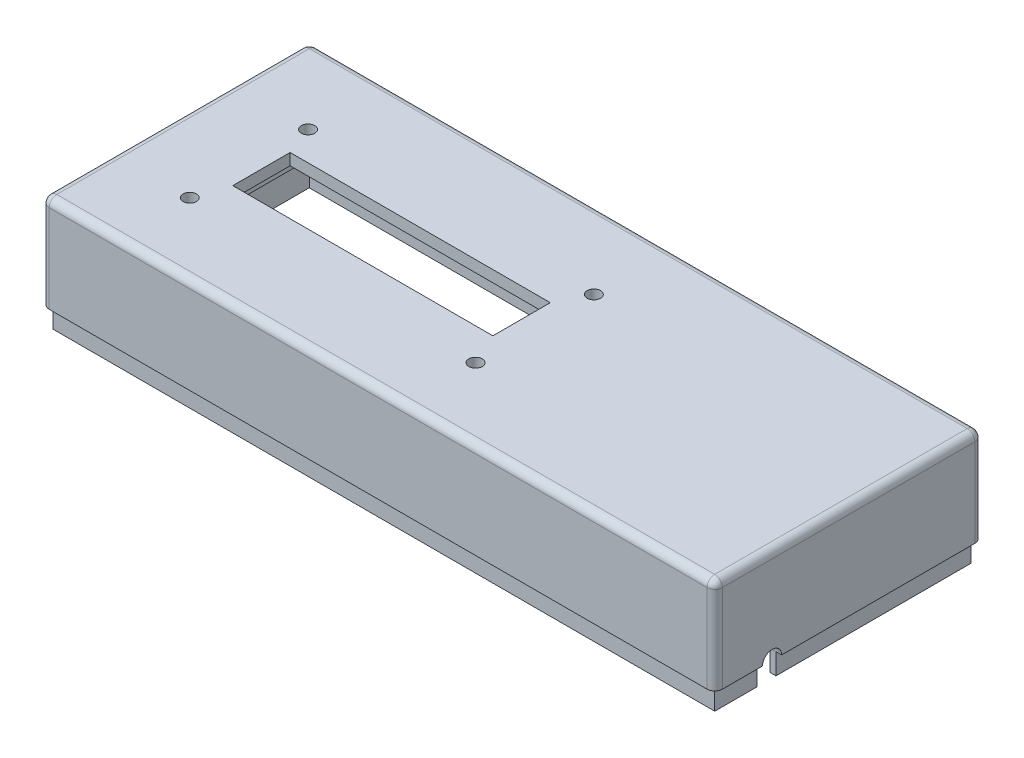
from build123d import *

# Parameters (mm, degrees)
SKETCH1_W           = 176
SKETCH1_H           = 70
BOSS_EXTRUDE1_DEPTH = 30.5
SKETCH2_W           = 170
SKETCH2_H           = 64
CUT_EXTRUDE1_DEPTH  = 27.5
SKETCH3_W           = 176
SKETCH3_H           = 70
SKETCH3_W_2         = 173
SKETCH3_H_2         = 67
CUT_EXTRUDE2_DEPTH  = 5.5
FILLET1_R           = 2
SKETCH4_W           = 78
SKETCH4_H           = 31
SKETCH4_W_2         = 72
SKETCH4_H_2         = 25
BOSS_EXTRUDE2_DEPTH = 3
CUT_EXTRUDE3_REACH  = 5
SKETCH5_W           = 68
SKETCH5_H           = 15
CUT_EXTRUDE4_REACH  = 32.5
SKETCH6_R           = 1.75
CUT_EXTRUDE6_REACH  = 178


with BuildPart() as part:
    # Sketch1 → Boss-Extrude1 (new body)
    with BuildSketch(Plane(origin=(0, 0, 0), x_dir=(1, 0, 0), z_dir=(0, 1, 0))):
        Rectangle(SKETCH1_W, SKETCH1_H)
    extrude(amount=BOSS_EXTRUDE1_DEPTH)

    # Sketch2 → Cut-Extrude1 (cut)
    with BuildSketch(Plane.XZ):
        Rectangle(SKETCH2_W, SKETCH2_H)
    extrude(amount=-CUT_EXTRUDE1_DEPTH, mode=Mode.SUBTRACT)

    # Sketch3 → Cut-Extrude2 (cut)
    with BuildSketch(Plane.XZ):
        Rectangle(SKETCH3_W, SKETCH3_H)
        Rectangle(SKETCH3_W_2, SKETCH3_H_2, mode=Mode.SUBTRACT)
    extrude(amount=-CUT_EXTRUDE2_DEPTH, mode=Mode.SUBTRACT)

    # Fillet1
    fillet1_edges = [part.edges().sort_by_distance(p)[0] for p in [
        (88, 30.5, 0),
        (0, 30.5, -35),
        (-88, 30.5, 0),
        (-88, 18, -35),
        (88, 18, -35),
        (88, 18, 35),
        (-88, 18, 35),
        (0, 30.5, 35),
    ]]
    fillet(fillet1_edges, radius=FILLET1_R)

    # Sketch4 → Boss-Extrude2 (add)
    with BuildSketch(Plane.XZ.offset(-27.5)):
        with Locations((-31, 0.5)):
            Rectangle(SKETCH4_W, SKETCH4_H)
        with Locations((-31, 0.5)):
            Rectangle(SKETCH4_W_2, SKETCH4_H_2, mode=Mode.SUBTRACT)
    extrude(amount=BOSS_EXTRUDE2_DEPTH)

    # Sketch5 → Cut-Extrude3 (cut, up to next)
    with BuildSketch(Plane.XZ.offset(-27.5), mode=Mode.PRIVATE) as cut_extrude3_sk1:
        with Locations((-31, 0.5)):
            Rectangle(SKETCH5_W, SKETCH5_H)
    cut_extrude3_tool1 = extrude(cut_extrude3_sk1.sketch, amount=-CUT_EXTRUDE3_REACH, mode=Mode.PRIVATE) & part.part
    add(cut_extrude3_tool1.solids().sort_by_distance((-31, 27.5, 0.5))[0], mode=Mode.SUBTRACT)

    # Sketch6 → Cut-Extrude4 (cut, up to next)
    with BuildSketch(Plane(origin=(0, 30.5, 0), x_dir=(1, 0, 0), z_dir=(0, 1, 0)), mode=Mode.PRIVATE) as cut_extrude4_sk1:
        with Locations((-67.88, 14.57)):
            Circle(SKETCH6_R)
    cut_extrude4_tool1 = extrude(cut_extrude4_sk1.sketch, amount=-CUT_EXTRUDE4_REACH, mode=Mode.PRIVATE) & part.part
    add(cut_extrude4_tool1.solids().sort_by_distance((-67.88, 30.5, -14.57))[0], mode=Mode.SUBTRACT)
    # Sketch6 → Cut-Extrude4 (cut, up to next)
    with BuildSketch(Plane(origin=(0, 30.5, 0), x_dir=(1, 0, 0), z_dir=(0, 1, 0)), mode=Mode.PRIVATE) as cut_extrude4_sk2:
        with Locations((6.83, 14.57)):
            Circle(SKETCH6_R)
    cut_extrude4_tool2 = extrude(cut_extrude4_sk2.sketch, amount=-CUT_EXTRUDE4_REACH, mode=Mode.PRIVATE) & part.part
    add(cut_extrude4_tool2.solids().sort_by_distance((6.83, 30.5, -14.57))[0], mode=Mode.SUBTRACT)
    # Sketch6 → Cut-Extrude4 (cut, up to next)
    with BuildSketch(Plane(origin=(0, 30.5, 0), x_dir=(1, 0, 0), z_dir=(0, 1, 0)), mode=Mode.PRIVATE) as cut_extrude4_sk3:
        with Locations((6.83, -16.36)):
            Circle(SKETCH6_R)
    cut_extrude4_tool3 = extrude(cut_extrude4_sk3.sketch, amount=-CUT_EXTRUDE4_REACH, mode=Mode.PRIVATE) & part.part
    add(cut_extrude4_tool3.solids().sort_by_distance((6.83, 30.5, 16.36))[0], mode=Mode.SUBTRACT)
    # Sketch6 → Cut-Extrude4 (cut, up to next)
    with BuildSketch(Plane(origin=(0, 30.5, 0), x_dir=(1, 0, 0), z_dir=(0, 1, 0)), mode=Mode.PRIVATE) as cut_extrude4_sk4:
        with Locations((-67.88, -16.36)):
            Circle(SKETCH6_R)
    cut_extrude4_tool4 = extrude(cut_extrude4_sk4.sketch, amount=-CUT_EXTRUDE4_REACH, mode=Mode.PRIVATE) & part.part
    add(cut_extrude4_tool4.solids().sort_by_distance((-67.88, 30.5, 16.36))[0], mode=Mode.SUBTRACT)

    # Sketch8 → Cut-Extrude6 (cut, up to next)
    with BuildSketch(Plane(origin=(88, 0, 0), x_dir=(0, 0, -1), z_dir=(1, 0, 0)), mode=Mode.PRIVATE) as cut_extrude6_sk1:
        with BuildLine():
            Line((-22.5, 5.5), (-22.5, 0))
            Line((-22.5, 0), (-17.5, 0))
            Line((-17.5, 0), (-17.5, 5.5))
            ThreePointArc((-17.5, 5.5), (-20, 8), (-22.5, 5.5))
        make_face()
    cut_extrude6_tool1 = extrude(cut_extrude6_sk1.sketch, amount=-CUT_EXTRUDE6_REACH, mode=Mode.PRIVATE) & part.part
    add(cut_extrude6_tool1.solids().sort_by_distance((88, 3.752606, 20))[0], mode=Mode.SUBTRACT)


solid = part.part
